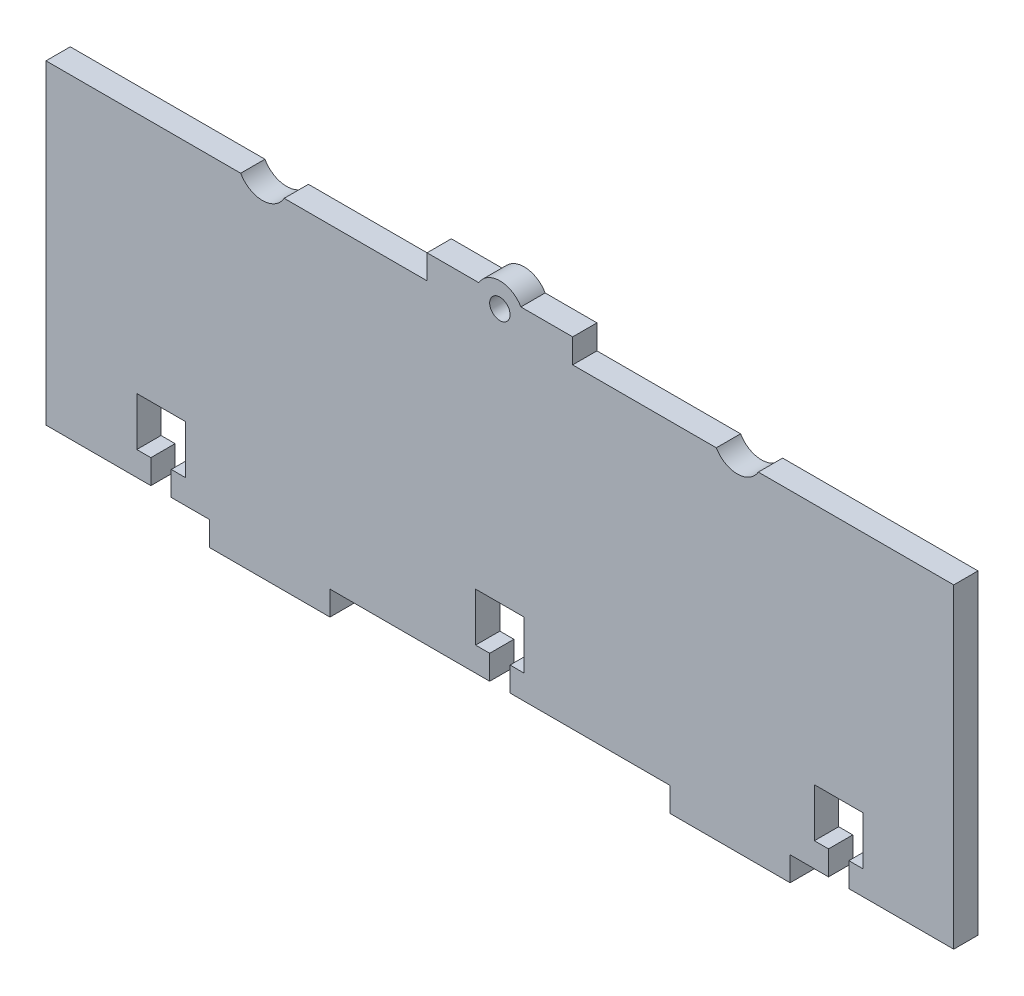
from build123d import *

# Parameters (mm, degrees)
BOSS_EXTRUDE1_DEPTH = 5
SKETCH2_W           = 35
SKETCH2_H           = 65
CUT_EXTRUDE1_DEPTH  = 10
SKETCH4_W           = 30
SKETCH4_H           = 5
BOSS_EXTRUDE2_DEPTH = 5
SKETCH5_W           = 20
SKETCH5_H           = 5
CUT_EXTRUDE3_DEPTH  = 5
SKETCH6_R           = 2.1
CUT_EXTRUDE4_DEPTH  = 5
BOSS_EXTRUDE3_DEPTH = 5
SKETCH8_W           = 4.2
SKETCH8_H           = 5
SKETCH8_W_2         = 10
SKETCH8_H_2         = 10
CUT_EXTRUDE5_DEPTH  = 5
SKETCH10_W          = 30
SKETCH10_H          = 10
CUT_EXTRUDE7_DEPTH  = 6
SKETCH11_W          = 15
SKETCH11_H          = 5
SKETCH11_W_2        = 5.2
CUT_EXTRUDE8_DEPTH  = 6
SKETCH13_W          = 8.5
SKETCH13_H          = 65
BOSS_EXTRUDE5_DEPTH = 5
SKETCH14_R          = 5
SKETCH14_R_2        = 5.12829824
CUT_EXTRUDE9_DEPTH  = 5


with BuildPart() as part:
    # Sketch1 → Boss-Extrude1 (new body)
    with BuildSketch(Plane.XY):
        Polygon((95, -5), (95, 0), (115, 0), (115, 20), (120, 20), (120, 45), (115, 45), (115, 65), (100, 65), (100, 70), (70, 70), (70, 65), (-70, 65), (-70, 70), (-100, 70), (-100, 65), (-115, 65), (-115, 45), (-120, 45), (-120, 20), (-115, 20), (-115, 0), (-95, 0), (-95, -5), (-35, -5), (-35, 0), (35, 0), (35, -5), align=None)
    extrude(amount=BOSS_EXTRUDE1_DEPTH)

    # Sketch2 → Cut-Extrude1 (cut)
    with BuildSketch(Plane(origin=(0, 0, 0), x_dir=(-1, 0, 0), z_dir=(0, 0, -1))):
        with Locations((102.5, 27.5)):
            Rectangle(SKETCH2_W, SKETCH2_H)
        with Locations((-102.5, 27.5)):
            Rectangle(SKETCH2_W, SKETCH2_H)
    extrude(amount=-CUT_EXTRUDE1_DEPTH, mode=Mode.SUBTRACT)

    # Sketch4 → Boss-Extrude2 (add)
    with BuildSketch(Plane(origin=(0, 65, 0), x_dir=(1, 0, 0), z_dir=(0, 1, 0))):
        with Locations((0, -2.5)):
            Rectangle(SKETCH4_W, SKETCH4_H)
    extrude(amount=BOSS_EXTRUDE2_DEPTH)

    # Sketch5 → Cut-Extrude3 (cut)
    with BuildSketch(Plane(origin=(0, 0, 0), x_dir=(-1, 0, 0), z_dir=(0, 0, -1))):
        with Locations((-69.8, -2.5)):
            Rectangle(SKETCH5_W, SKETCH5_H)
        with Locations((69.8, -2.5)):
            Rectangle(SKETCH5_W, SKETCH5_H)
    extrude(amount=-CUT_EXTRUDE3_DEPTH, mode=Mode.SUBTRACT)

    # Sketch6 → Cut-Extrude4 (cut)
    with BuildSketch(Plane(origin=(0, 0, 0), x_dir=(-1, 0, 0), z_dir=(0, 0, -1))):
        with Locations((0, 67.5)):
            Circle(SKETCH6_R)
    extrude(amount=-CUT_EXTRUDE4_DEPTH, mode=Mode.SUBTRACT)

    # Sketch7 → Boss-Extrude3 (add)
    with BuildSketch(Plane(origin=(0, 0, 0), x_dir=(-1, 0, 0), z_dir=(0, 0, -1))):
        with BuildLine():
            Line((4.330127019, 70), (-4.330127019, 70))
            ThreePointArc((-4.330127019, 70), (0, 72.5), (4.330127019, 70))
        make_face()
    extrude(amount=-BOSS_EXTRUDE3_DEPTH)

    # Sketch8 → Cut-Extrude5 (cut)
    with BuildSketch(Plane(origin=(0, 0, 0), x_dir=(-1, 0, 0), z_dir=(0, 0, -1))):
        with Locations((69.8, 2.5)):
            Rectangle(SKETCH8_W, SKETCH8_H)
        with Locations((69.8, 10)):
            Rectangle(SKETCH8_W_2, SKETCH8_H_2)
        with Locations((-69.8, 10)):
            Rectangle(SKETCH8_W_2, SKETCH8_H_2)
        with Locations((-69.8, 2.5)):
            Rectangle(SKETCH8_W, SKETCH8_H)
        with Locations((0, 2.5)):
            Rectangle(SKETCH8_W, SKETCH8_H)
        with Locations((0, 10)):
            Rectangle(SKETCH8_W_2, SKETCH8_H_2)
    extrude(amount=-CUT_EXTRUDE5_DEPTH, mode=Mode.SUBTRACT)

    # Sketch10 → Cut-Extrude7 (cut, through all)
    with BuildSketch(Plane(origin=(0, 0, 0), x_dir=(-1, 0, 0), z_dir=(0, 0, -1))):
        with Locations((-100, 65)):
            Rectangle(SKETCH10_W, SKETCH10_H)
        with Locations((100, 65)):
            Rectangle(SKETCH10_W, SKETCH10_H)
    extrude(amount=-CUT_EXTRUDE7_DEPTH, mode=Mode.SUBTRACT)

    # Sketch11 → Cut-Extrude8 (cut, through all)
    with BuildSketch(Plane(origin=(0, 0, 0), x_dir=(-1, 0, 0), z_dir=(0, 0, -1))):
        with Locations((-77.5, 67.5)):
            Rectangle(SKETCH11_W, SKETCH11_H)
        with Locations((77.5, 67.5)):
            Rectangle(SKETCH11_W, SKETCH11_H)
        with Locations((82.4, -2.5)):
            Rectangle(SKETCH11_W_2, SKETCH11_H)
        with Locations((-82.4, -2.5)):
            Rectangle(SKETCH11_W_2, SKETCH11_H)
    extrude(amount=-CUT_EXTRUDE8_DEPTH, mode=Mode.SUBTRACT)

    # Sketch13 → Boss-Extrude5 (add)
    with BuildSketch(Plane(origin=(0, 0, 0), x_dir=(-1, 0, 0), z_dir=(0, 0, -1))):
        with Locations((-89.25, 32.5)):
            Rectangle(SKETCH13_W, SKETCH13_H)
        with Locations((89.25, 32.5)):
            Rectangle(SKETCH13_W, SKETCH13_H)
    extrude(amount=-BOSS_EXTRUDE5_DEPTH)

    # Sketch14 → Cut-Extrude9 (cut)
    with BuildSketch(Plane(origin=(0, 0, 0), x_dir=(-1, 0, 0), z_dir=(0, 0, -1))):
        with Locations((-48.915063509, 67.5)):
            Circle(SKETCH14_R)
        with Locations((48.915063509, 67.5)):
            Circle(SKETCH14_R_2)
    extrude(amount=-CUT_EXTRUDE9_DEPTH, mode=Mode.SUBTRACT)


solid = part.part
